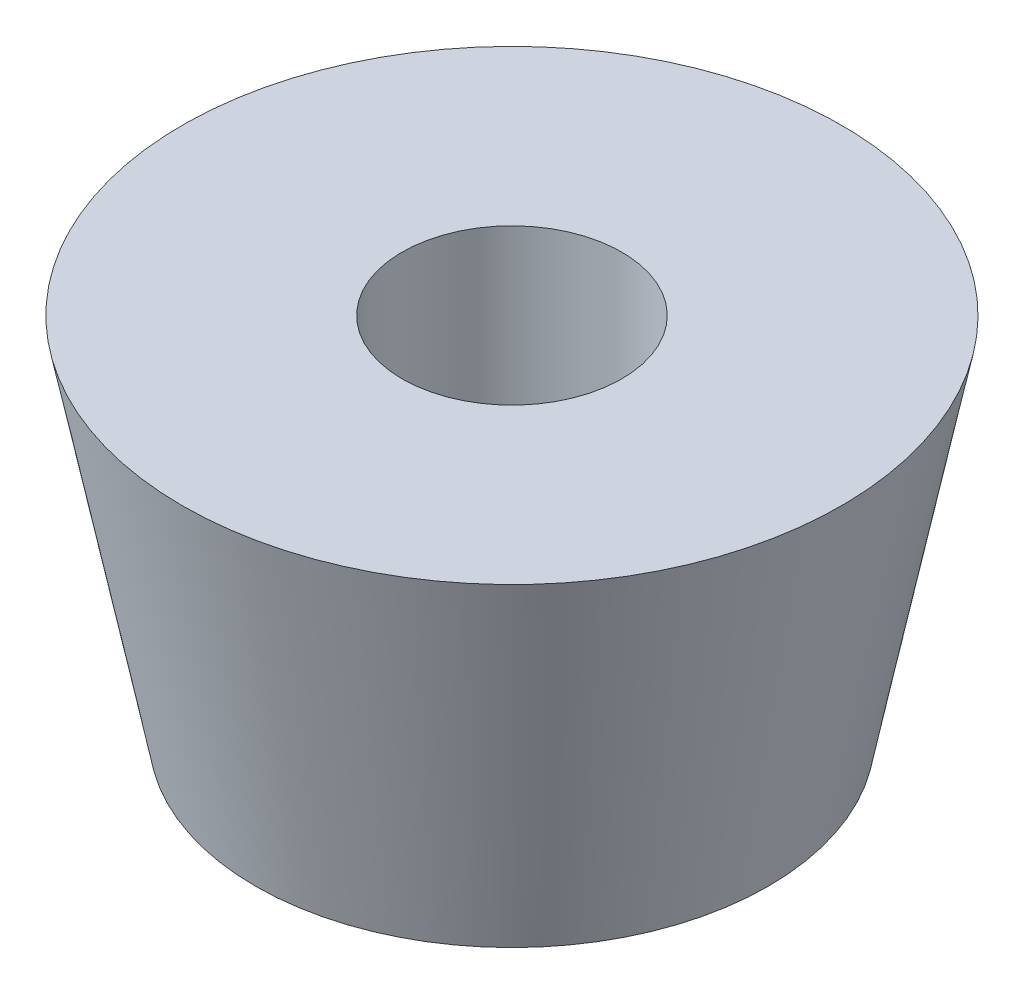
from build123d import *


with BuildPart() as part:
    # Sketch1 → Revolve1 (revolve)
    with BuildSketch(Plane(origin=(0, 0, 0), x_dir=(0, 0, -1), z_dir=(1, 0, 0))):
        Polygon((1.5, 0), (1.5, -5), (3.5, -5), (4.5, 0), align=None)
    revolve(axis=Axis((0, 0, 0), (0, -1, 0)))


solid = part.part
